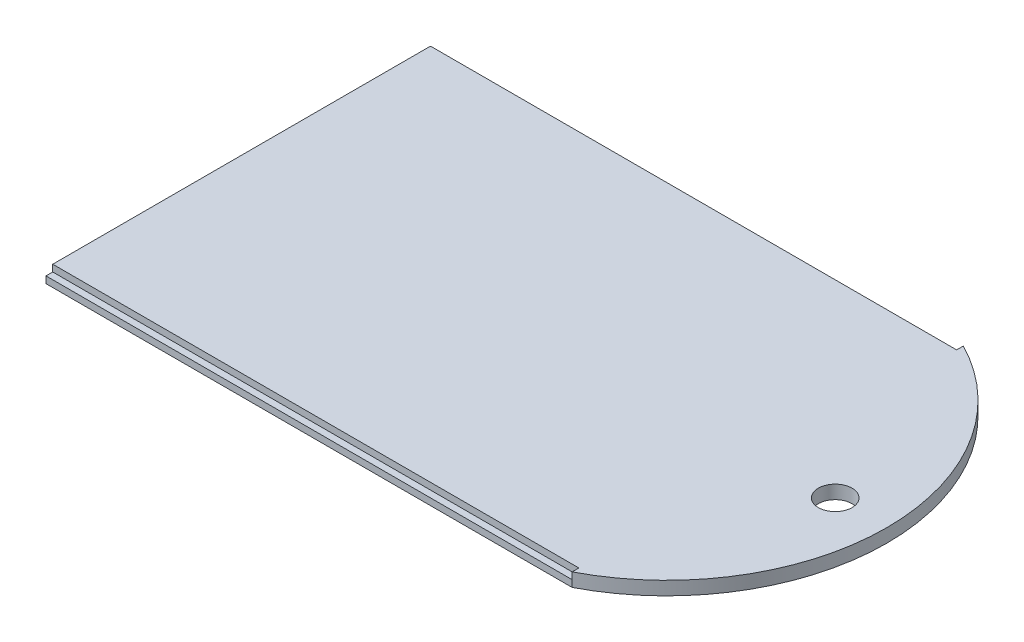
from build123d import *

# Parameters (mm, degrees)
SKIZZE1_R                       = 2.5
AUFSATZ_LINEAR_AUSTRAGEN1_DEPTH = 2
SKIZZE2_W                       = 78
SKIZZE2_H                       = 1
SCHNITT_LINEAR_AUSTRAGEN1_DEPTH = 1


with BuildPart() as part:
    # Skizze1 → Aufsatz-Linear austragen1 (new body)
    with BuildSketch(Plane(origin=(0, 0, 0), x_dir=(1, 0, 0), z_dir=(0, 1, 0))):
        with BuildLine():
            Line((0, 0), (78, 0))
            ThreePointArc((78, 0), (95.649655435, 29), (78, 58))
            Line((78, 58), (0, 58))
            Line((0, 58), (0, 0))
        make_face()
        with Locations((88, 29)):
            Circle(SKIZZE1_R, mode=Mode.SUBTRACT)
    extrude(amount=AUFSATZ_LINEAR_AUSTRAGEN1_DEPTH)

    # Skizze2 → Schnitt-Linear austragen1 (cut)
    with BuildSketch(Plane(origin=(0, 2, 0), x_dir=(1, 0, 0), z_dir=(0, 1, 0))):
        with Locations((39, 57.5)):
            Rectangle(SKIZZE2_W, SKIZZE2_H)
        with Locations((39, 0.5)):
            Rectangle(SKIZZE2_W, SKIZZE2_H)
    extrude(amount=-SCHNITT_LINEAR_AUSTRAGEN1_DEPTH, mode=Mode.SUBTRACT)


solid = part.part
